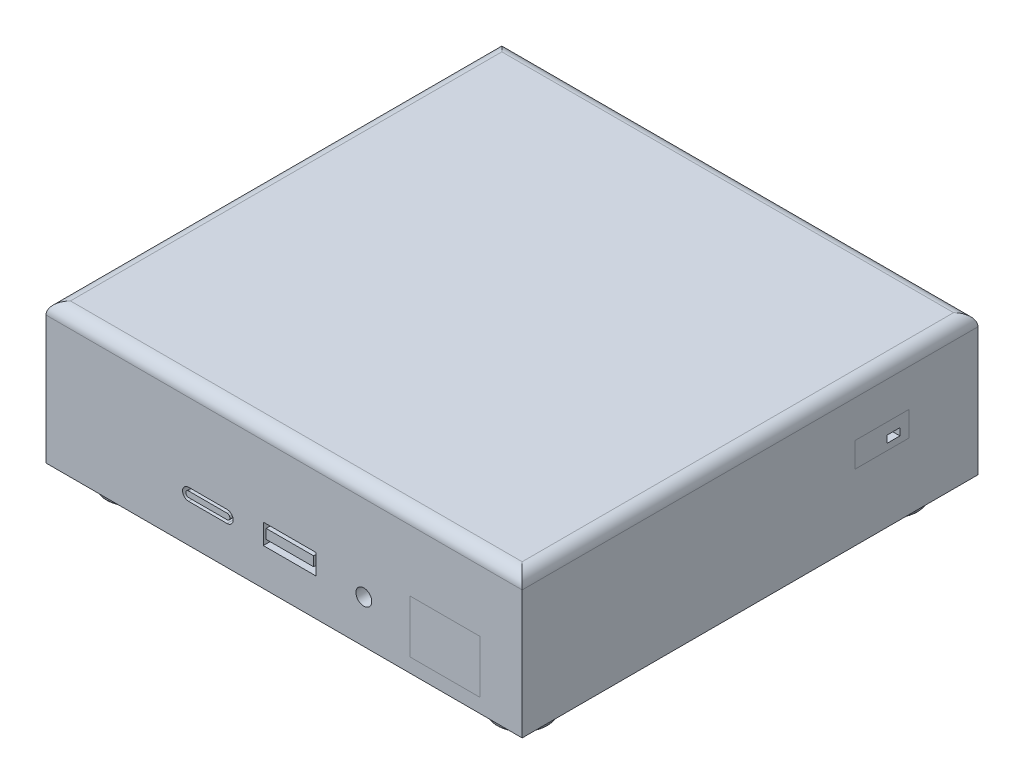
from build123d import *

# Parameters (mm, degrees)
SKETCH_2_W          = 117
SKETCH_2_H          = 112
EXTRUDE_1_DEPTH     = 34.5
FILLET_1_R          = 3
SKETCH_5_R          = 1.94319569
SKETCH_5_W          = 13
SKETCH_5_H          = 5
SKETCH_5_W_2        = 11.655581837
SKETCH_5_H_2        = 2.33697436
CUT_EXTRUDE_1_DEPTH = 34.5
SKETCH_7_W          = 3.12128514
SKETCH_7_H          = 1.749384405
CUT_EXTRUDE_2_DEPTH = 34.5
SKETCH_9_W          = 12.023305714
SKETCH_9_H          = 0.702782293
SKETCH_9_R          = 3.105468951
SKETCH_9_R_2        = 1.268882641
SKETCH_9_W_2        = 12.933693937
SKETCH_9_H_2        = 7.702330062
SKETCH_9_W_3        = 7.704150903
SKETCH_9_H_3        = 2.128244441
SKETCH_9_W_4        = 10.462177884
SKETCH_9_H_4        = 5.279264431
SKETCH_9_W_5        = 7
SKETCH_9_H_5        = 1.91211105
SKETCH_9_H_6        = 5.213763305
SKETCH_9_H_7        = 1.542759432
CUT_EXTRUDE_3_DEPTH = 34.5
SKETCH_11_W         = 26.414855416
SKETCH_11_H         = 1.499589485
CUT_EXTRUDE_4_DEPTH = 34.5
SKETCH_13_R         = 6.25
EXTRUDE_2_DEPTH     = 5
SKETCH_14_R         = 4
CUT_EXTRUDE_5_DEPTH = 5
SKETCH_15_R         = 1.5
CUT_EXTRUDE_6_DEPTH = 5
CUT_EXTRUDE_7_DEPTH = 1
FILLET_2_R          = 3
FILLET_3_R          = 0.5
SKETCH_17_R         = 1.25
CUT_EXTRUDE_8_DEPTH = 10


with BuildPart() as part:
    # 草图2 → 凸台-拉伸1 (new body)
    with BuildSketch(Plane(origin=(0, 0, 0), x_dir=(1, 0, 0), z_dir=(0, 1, 0))):
        Rectangle(SKETCH_2_W, SKETCH_2_H)
    extrude(amount=EXTRUDE_1_DEPTH)

    # 圆角1
    fillet_1_edges = [part.edges().sort_by_distance(p)[0] for p in [
        (-58.5, 34.5, 0),
        (0, 34.5, 56),
        (58.5, 34.5, 0),
        (0, 34.5, -56),
    ]]
    fillet(fillet_1_edges, radius=FILLET_1_R)

    # 草图5 → 切除-拉伸1 (cut)
    with BuildSketch(Plane.XY.offset(56)):
        with Locations((19.594569858, 10.537289657)):
            Circle(SKETCH_5_R)
        with Locations((1.387582533, 11.639469252)):
            Rectangle(SKETCH_5_W, SKETCH_5_H)
        with Locations((1.418326707, 11.970982072)):
            Rectangle(SKETCH_5_W_2, SKETCH_5_H_2, mode=Mode.SUBTRACT)
        with BuildLine():
            Line((-23.453277439, 12.376301325), (-14.013410674, 12.376301325))
            ThreePointArc((-14.013410674, 12.376301325), (-12.513410674, 10.876301325), (-14.013410674, 9.376301325))
            Line((-14.013410674, 9.376301325), (-23.453277439, 9.376301325))
            ThreePointArc((-23.453277439, 9.376301325), (-24.953277439, 10.876301325), (-23.453277439, 12.376301325))
        make_face()
        with BuildLine():
            Line((-23.453277439, 11.576301325), (-14.013410674, 11.576301325))
            ThreePointArc((-14.013410674, 11.576301325), (-13.313410674, 10.876301325), (-14.013410674, 10.176301325))
            Line((-14.013410674, 10.176301325), (-23.453277439, 10.176301325))
            ThreePointArc((-23.453277439, 10.176301325), (-24.153277439, 10.876301325), (-23.453277439, 11.576301325))
        make_face(mode=Mode.SUBTRACT)
    extrude(amount=-CUT_EXTRUDE_1_DEPTH, mode=Mode.SUBTRACT)

    # 草图7 → 切除-拉伸2 (cut)
    with BuildSketch(Plane(origin=(58.5, 0, 0), x_dir=(0, 0, -1), z_dir=(1, 0, 0))):
        with Locations((35.251062041, 18.745661738)):
            Rectangle(SKETCH_7_W, SKETCH_7_H)
    extrude(amount=-CUT_EXTRUDE_2_DEPTH, mode=Mode.SUBTRACT)

    # 草图9 → 切除-拉伸3 (cut)
    with BuildSketch(Plane(origin=(0, 0, -56), x_dir=(-1, 0, 0), z_dir=(0, 0, -1))):
        with BuildLine():
            ThreePointArc((-35.950498544, 11.544599726), (-34.777577949, 12.001879174), (-34.223677194, 13.132384002))
            Line((-34.223677194, 13.132384002), (-27.359684331, 13.132384002))
            Line((-27.359684331, 13.132384002), (-19.927828097, 13.132384002))
            ThreePointArc((-19.927828097, 13.132384002), (-19.656996341, 12.194159761), (-18.927828097, 11.544599726))
            Line((-18.927828097, 11.544599726), (-18.927828097, 8.613731529))
            Line((-18.927828097, 8.613731529), (-35.950498544, 8.613731529))
            Line((-35.950498544, 8.613731529), (-35.950498544, 11.544599726))
        make_face()
        with Locations((-26.730939637, 10.073758574)):
            Rectangle(SKETCH_9_W, SKETCH_9_H, mode=Mode.SUBTRACT)
        with Locations((-47.942536707, 10.42514972)):
            Circle(SKETCH_9_R)
        with Locations((-47.942536707, 10.42514972)):
            Circle(SKETCH_9_R_2, mode=Mode.SUBTRACT)
        with Locations((-3.756830225, 12.46489656)):
            Rectangle(SKETCH_9_W_2, SKETCH_9_H_2)
        with Locations((-3.075752646, 7.549609309)):
            Rectangle(SKETCH_9_W_3, SKETCH_9_H_3)
        with Locations((16.303260845, 13.676429375)):
            Rectangle(SKETCH_9_W_4, SKETCH_9_H_4)
        with Locations((16.276322806, 14.632484901)):
            Rectangle(SKETCH_9_W_5, SKETCH_9_H_5, mode=Mode.SUBTRACT)
        with Locations((16.303260845, 6.006849877)):
            Rectangle(SKETCH_9_W_4, SKETCH_9_H_6)
        with Locations((16.276322806, 6.778229593)):
            Rectangle(SKETCH_9_W_5, SKETCH_9_H_7, mode=Mode.SUBTRACT)
        with BuildLine():
            Line((31.367178921, 13.835844061), (38.401088463, 13.835844061))
            ThreePointArc((38.401088463, 13.835844061), (40.153784829, 15.588540426), (38.401088463, 17.341236792))
            Line((38.401088463, 17.341236792), (31.367178921, 17.341236792))
            ThreePointArc((31.367178921, 17.341236792), (29.614482555, 15.588540426), (31.367178921, 13.835844061))
        make_face()
        with BuildLine():
            ThreePointArc((38.401088463, 15.199333705), (38.790295184, 15.588540426), (38.401088463, 15.977747147))
            Line((38.401088463, 15.977747147), (31.367178921, 15.977747147))
            ThreePointArc((31.367178921, 15.977747147), (30.977972199, 15.588540426), (31.367178921, 15.199333705))
            Line((31.367178921, 15.199333705), (38.401088463, 15.199333705))
        make_face(mode=Mode.SUBTRACT)
        with BuildLine():
            Line((35.072171903, 20.278921559), (36.776322806, 20.278921559))
            ThreePointArc((36.776322806, 20.278921559), (37.483429588, 20.571814778), (37.776322806, 21.278921559))
            Line((37.776322806, 21.278921559), (37.776322806, 26.966804486))
            ThreePointArc((37.776322806, 26.966804486), (37.483429588, 27.673911268), (36.776322806, 27.966804486))
            Line((36.776322806, 27.966804486), (35.072171903, 27.966804486))
            ThreePointArc((35.072171903, 27.966804486), (34.365065122, 27.673911268), (34.072171903, 26.966804486))
            Line((34.072171903, 26.966804486), (34.072171903, 21.278921559))
            ThreePointArc((34.072171903, 21.278921559), (34.365065122, 20.571814778), (35.072171903, 20.278921559))
        make_face()
        with BuildLine():
            Line((29.072171903, 20.278921559), (30.776322806, 20.278921559))
            ThreePointArc((30.776322806, 20.278921559), (31.483429588, 20.571814778), (31.776322806, 21.278921559))
            Line((31.776322806, 21.278921559), (31.776322806, 26.966804486))
            ThreePointArc((31.776322806, 26.966804486), (31.483429588, 27.673911268), (30.776322806, 27.966804486))
            Line((30.776322806, 27.966804486), (29.072171903, 27.966804486))
            ThreePointArc((29.072171903, 27.966804486), (28.365065122, 27.673911268), (28.072171903, 26.966804486))
            Line((28.072171903, 26.966804486), (28.072171903, 21.278921559))
            ThreePointArc((28.072171903, 21.278921559), (28.365065122, 20.571814778), (29.072171903, 20.278921559))
        make_face()
        with BuildLine():
            Line((23.072171903, 20.278921559), (24.776322806, 20.278921559))
            ThreePointArc((24.776322806, 20.278921559), (25.483429588, 20.571814778), (25.776322806, 21.278921559))
            Line((25.776322806, 21.278921559), (25.776322806, 26.966804486))
            ThreePointArc((25.776322806, 26.966804486), (25.483429588, 27.673911268), (24.776322806, 27.966804486))
            Line((24.776322806, 27.966804486), (23.072171903, 27.966804486))
            ThreePointArc((23.072171903, 27.966804486), (22.365065122, 27.673911268), (22.072171903, 26.966804486))
            Line((22.072171903, 26.966804486), (22.072171903, 21.278921559))
            ThreePointArc((22.072171903, 21.278921559), (22.365065122, 20.571814778), (23.072171903, 20.278921559))
        make_face()
        with BuildLine():
            Line((17.072171903, 20.278921559), (18.776322806, 20.278921559))
            ThreePointArc((18.776322806, 20.278921559), (19.483429588, 20.571814778), (19.776322806, 21.278921559))
            Line((19.776322806, 21.278921559), (19.776322806, 26.966804486))
            ThreePointArc((19.776322806, 26.966804486), (19.483429588, 27.673911268), (18.776322806, 27.966804486))
            Line((18.776322806, 27.966804486), (17.072171903, 27.966804486))
            ThreePointArc((17.072171903, 27.966804486), (16.365065122, 27.673911268), (16.072171903, 26.966804486))
            Line((16.072171903, 26.966804486), (16.072171903, 21.278921559))
            ThreePointArc((16.072171903, 21.278921559), (16.365065122, 20.571814778), (17.072171903, 20.278921559))
        make_face()
        with BuildLine():
            Line((11.072171903, 20.278921559), (12.776322806, 20.278921559))
            ThreePointArc((12.776322806, 20.278921559), (13.483429588, 20.571814778), (13.776322806, 21.278921559))
            Line((13.776322806, 21.278921559), (13.776322806, 26.966804486))
            ThreePointArc((13.776322806, 26.966804486), (13.483429588, 27.673911268), (12.776322806, 27.966804486))
            Line((12.776322806, 27.966804486), (11.072171903, 27.966804486))
            ThreePointArc((11.072171903, 27.966804486), (10.365065122, 27.673911268), (10.072171903, 26.966804486))
            Line((10.072171903, 26.966804486), (10.072171903, 21.278921559))
            ThreePointArc((10.072171903, 21.278921559), (10.365065122, 20.571814778), (11.072171903, 20.278921559))
        make_face()
        with BuildLine():
            Line((5.072171903, 20.278921559), (6.776322806, 20.278921559))
            ThreePointArc((6.776322806, 20.278921559), (7.483429588, 20.571814778), (7.776322806, 21.278921559))
            Line((7.776322806, 21.278921559), (7.776322806, 26.966804486))
            ThreePointArc((7.776322806, 26.966804486), (7.483429588, 27.673911268), (6.776322806, 27.966804486))
            Line((6.776322806, 27.966804486), (5.072171903, 27.966804486))
            ThreePointArc((5.072171903, 27.966804486), (4.365065122, 27.673911268), (4.072171903, 26.966804486))
            Line((4.072171903, 26.966804486), (4.072171903, 21.278921559))
            ThreePointArc((4.072171903, 21.278921559), (4.365065122, 20.571814778), (5.072171903, 20.278921559))
        make_face()
        with BuildLine():
            Line((-0.927828097, 20.278921559), (0.776322806, 20.278921559))
            ThreePointArc((0.776322806, 20.278921559), (1.483429588, 20.571814778), (1.776322806, 21.278921559))
            Line((1.776322806, 21.278921559), (1.776322806, 26.966804486))
            ThreePointArc((1.776322806, 26.966804486), (1.483429588, 27.673911268), (0.776322806, 27.966804486))
            Line((0.776322806, 27.966804486), (-0.927828097, 27.966804486))
            ThreePointArc((-0.927828097, 27.966804486), (-1.634934878, 27.673911268), (-1.927828097, 26.966804486))
            Line((-1.927828097, 26.966804486), (-1.927828097, 21.278921559))
            ThreePointArc((-1.927828097, 21.278921559), (-1.634934878, 20.571814778), (-0.927828097, 20.278921559))
        make_face()
        with BuildLine():
            Line((-6.927828097, 20.278921559), (-5.223677194, 20.278921559))
            ThreePointArc((-5.223677194, 20.278921559), (-4.516570412, 20.571814778), (-4.223677194, 21.278921559))
            Line((-4.223677194, 21.278921559), (-4.223677194, 26.966804486))
            ThreePointArc((-4.223677194, 26.966804486), (-4.516570412, 27.673911268), (-5.223677194, 27.966804486))
            Line((-5.223677194, 27.966804486), (-6.927828097, 27.966804486))
            ThreePointArc((-6.927828097, 27.966804486), (-7.634934878, 27.673911268), (-7.927828097, 26.966804486))
            Line((-7.927828097, 26.966804486), (-7.927828097, 21.278921559))
            ThreePointArc((-7.927828097, 21.278921559), (-7.634934878, 20.571814778), (-6.927828097, 20.278921559))
        make_face()
        with BuildLine():
            Line((-12.927828097, 20.278921559), (-11.223677194, 20.278921559))
            ThreePointArc((-11.223677194, 20.278921559), (-10.516570412, 20.571814778), (-10.223677194, 21.278921559))
            Line((-10.223677194, 21.278921559), (-10.223677194, 26.966804486))
            ThreePointArc((-10.223677194, 26.966804486), (-10.516570412, 27.673911268), (-11.223677194, 27.966804486))
            Line((-11.223677194, 27.966804486), (-12.927828097, 27.966804486))
            ThreePointArc((-12.927828097, 27.966804486), (-13.634934878, 27.673911268), (-13.927828097, 26.966804486))
            Line((-13.927828097, 26.966804486), (-13.927828097, 21.278921559))
            ThreePointArc((-13.927828097, 21.278921559), (-13.634934878, 20.571814778), (-12.927828097, 20.278921559))
        make_face()
        with BuildLine():
            Line((-18.927828097, 20.278921559), (-17.223677194, 20.278921559))
            ThreePointArc((-17.223677194, 20.278921559), (-16.516570412, 20.571814778), (-16.223677194, 21.278921559))
            Line((-16.223677194, 21.278921559), (-16.223677194, 26.966804486))
            ThreePointArc((-16.223677194, 26.966804486), (-16.516570412, 27.673911268), (-17.223677194, 27.966804486))
            Line((-17.223677194, 27.966804486), (-18.927828097, 27.966804486))
            ThreePointArc((-18.927828097, 27.966804486), (-19.634934878, 27.673911268), (-19.927828097, 26.966804486))
            Line((-19.927828097, 26.966804486), (-19.927828097, 21.278921559))
            ThreePointArc((-19.927828097, 21.278921559), (-19.634934878, 20.571814778), (-18.927828097, 20.278921559))
        make_face()
        with BuildLine():
            Line((-24.927828097, 20.278921559), (-23.223677194, 20.278921559))
            ThreePointArc((-23.223677194, 20.278921559), (-22.516570412, 20.571814778), (-22.223677194, 21.278921559))
            Line((-22.223677194, 21.278921559), (-22.223677194, 26.966804486))
            ThreePointArc((-22.223677194, 26.966804486), (-22.516570412, 27.673911268), (-23.223677194, 27.966804486))
            Line((-23.223677194, 27.966804486), (-24.927828097, 27.966804486))
            ThreePointArc((-24.927828097, 27.966804486), (-25.634934878, 27.673911268), (-25.927828097, 26.966804486))
            Line((-25.927828097, 26.966804486), (-25.927828097, 21.278921559))
            ThreePointArc((-25.927828097, 21.278921559), (-25.634934878, 20.571814778), (-24.927828097, 20.278921559))
        make_face()
        with BuildLine():
            Line((-30.927828097, 20.278921559), (-29.223677194, 20.278921559))
            ThreePointArc((-29.223677194, 20.278921559), (-28.516570412, 20.571814778), (-28.223677194, 21.278921559))
            Line((-28.223677194, 21.278921559), (-28.223677194, 26.966804486))
            ThreePointArc((-28.223677194, 26.966804486), (-28.516570412, 27.673911268), (-29.223677194, 27.966804486))
            Line((-29.223677194, 27.966804486), (-30.927828097, 27.966804486))
            ThreePointArc((-30.927828097, 27.966804486), (-31.634934878, 27.673911268), (-31.927828097, 26.966804486))
            Line((-31.927828097, 26.966804486), (-31.927828097, 21.278921559))
            ThreePointArc((-31.927828097, 21.278921559), (-31.634934878, 20.571814778), (-30.927828097, 20.278921559))
        make_face()
        with BuildLine():
            Line((-36.927828097, 20.278921559), (-35.223677194, 20.278921559))
            ThreePointArc((-35.223677194, 20.278921559), (-34.516570412, 20.571814778), (-34.223677194, 21.278921559))
            Line((-34.223677194, 21.278921559), (-34.223677194, 26.966804486))
            ThreePointArc((-34.223677194, 26.966804486), (-34.516570412, 27.673911268), (-35.223677194, 27.966804486))
            Line((-35.223677194, 27.966804486), (-36.927828097, 27.966804486))
            ThreePointArc((-36.927828097, 27.966804486), (-37.634934878, 27.673911268), (-37.927828097, 26.966804486))
            Line((-37.927828097, 26.966804486), (-37.927828097, 21.278921559))
            ThreePointArc((-37.927828097, 21.278921559), (-37.634934878, 20.571814778), (-36.927828097, 20.278921559))
        make_face()
        with BuildLine():
            ThreePointArc((-43.927828097, 26.966804486), (-43.634934878, 27.673911268), (-42.927828097, 27.966804486))
            Line((-42.927828097, 27.966804486), (-41.223677194, 27.966804486))
            ThreePointArc((-41.223677194, 27.966804486), (-40.516570412, 27.673911268), (-40.223677194, 26.966804486))
            Line((-40.223677194, 26.966804486), (-40.223677194, 21.278921559))
            ThreePointArc((-40.223677194, 21.278921559), (-40.516570412, 20.571814778), (-41.223677194, 20.278921559))
            Line((-41.223677194, 20.278921559), (-42.927828097, 20.278921559))
            ThreePointArc((-42.927828097, 20.278921559), (-43.634934878, 20.571814778), (-43.927828097, 21.278921559))
            Line((-43.927828097, 21.278921559), (-43.927828097, 26.966804486))
        make_face()
    extrude(amount=-CUT_EXTRUDE_3_DEPTH, mode=Mode.SUBTRACT)

    # 草图11 → 切除-拉伸4 (cut)
    with BuildSketch(Plane.ZY.offset(58.5)):
        with Locations((27.293913372, 15.341122477)):
            Rectangle(SKETCH_11_W, SKETCH_11_H)
    extrude(amount=-CUT_EXTRUDE_4_DEPTH, mode=Mode.SUBTRACT)

    # 草图13 → 凸台-拉伸2 (add)
    with BuildSketch(Plane.XZ):
        with Locations((48, 45.5)):
            Circle(SKETCH_13_R)
        with Locations((48, -45.5)):
            Circle(SKETCH_13_R)
        with Locations((-48, 45.5)):
            Circle(SKETCH_13_R)
        with Locations((-48, -45.5)):
            Circle(SKETCH_13_R)
    extrude(amount=EXTRUDE_2_DEPTH)

    # 草图14 → 切除-拉伸5 (cut)
    with BuildSketch(Plane.XZ.offset(5)):
        with Locations((48, 45.5)):
            Circle(SKETCH_14_R)
        with Locations((48, -45.5)):
            Circle(SKETCH_14_R)
        with Locations((-48, 45.5)):
            Circle(SKETCH_14_R)
        with Locations((-48, -45.5)):
            Circle(SKETCH_14_R)
    extrude(amount=-CUT_EXTRUDE_5_DEPTH, mode=Mode.SUBTRACT)

    # 草图15 → 切除-拉伸6 (cut)
    with BuildSketch(Plane.XZ):
        with Locations((0, 42.5)):
            Circle(SKETCH_15_R)
        with Locations((0, -42.5)):
            Circle(SKETCH_15_R)
    extrude(amount=-CUT_EXTRUDE_6_DEPTH, mode=Mode.SUBTRACT)

    # 草图16 → 切除-拉伸7 (cut)
    with BuildSketch(Plane.XZ):
        with BuildLine():
            ThreePointArc((33, -45.5), (37.393398282, -34.893398282), (48, -30.5))
            Line((48, -30.5), (48, 30.5))
            ThreePointArc((48, 30.5), (37.393398282, 34.893398282), (33, 45.5))
            Line((33, 45.5), (11.971550157, 45.5))
            Line((11.971550157, 45.5), (4.383302564, 37.30509973))
            Line((4.383302564, 37.30509973), (3.340411246, 37.30509973))
            Line((3.340411246, 37.30509973), (-3.340411246, 37.30509973))
            Line((-3.340411246, 37.30509973), (-4.383302564, 37.30509973))
            Line((-4.383302564, 37.30509973), (-11.971550157, 45.5))
            Line((-11.971550157, 45.5), (-33, 45.5))
            ThreePointArc((-33, 45.5), (-37.393398282, 34.893398282), (-48, 30.5))
            Line((-48, 30.5), (-48, -30.5))
            ThreePointArc((-48, -30.5), (-37.393398282, -34.893398282), (-33, -45.5))
            Line((-33, -45.5), (-11.971550157, -45.5))
            Line((-11.971550157, -45.5), (-4.383302564, -37.30509973))
            Line((-4.383302564, -37.30509973), (-3.340411246, -37.30509973))
            Line((-3.340411246, -37.30509973), (3.340411246, -37.30509973))
            Line((3.340411246, -37.30509973), (4.383302564, -37.30509973))
            Line((4.383302564, -37.30509973), (11.971550157, -45.5))
            Line((11.971550157, -45.5), (33, -45.5))
        make_face()
    extrude(amount=-CUT_EXTRUDE_7_DEPTH, mode=Mode.SUBTRACT)

    # 圆角2
    fillet_2_edges = [part.edges().sort_by_distance(p)[0] for p in [
        (-48, 0.5, 30.5),
        (-33, 0.5, 45.5),
        (-11.971550157, 0.5, 45.5),
        (-4.383302564, 0.5, 37.30509973),
        (4.383302564, 0.5, 37.30509973),
        (11.971550157, 0.5, 45.5),
        (33, 0.5, 45.5),
        (48, 0.5, 30.5),
        (48, 0.5, -30.5),
        (33, 0.5, -45.5),
        (11.971550157, 0.5, -45.5),
        (4.383302564, 0.5, -37.30509973),
        (-4.383302564, 0.5, -37.30509973),
        (-11.971550157, 0.5, -45.5),
        (-33, 0.5, -45.5),
        (-48, 0.5, -30.5),
    ]]
    fillet(fillet_2_edges, radius=FILLET_2_R)

    # 圆角3
    fillet_3_edges = [part.edges().sort_by_distance(p)[0] for p in [
        (41.75, -5, 45.5),
        (41.75, -5, -45.5),
        (-54.25, -5, 45.5),
        (-54.25, -5, -45.5),
        (44, -5, -45.5),
        (-52, -5, 45.5),
        (-52, -5, -45.5),
        (44, -5, 45.5),
    ]]
    fillet(fillet_3_edges, radius=FILLET_3_R)

    # 草图17 → 切除-拉伸8 (cut)
    with BuildSketch(Plane.XZ):
        with Locations((48, 45.5)):
            Circle(SKETCH_17_R)
        with Locations((48, -45.5)):
            Circle(SKETCH_17_R)
        with Locations((-48, 45.5)):
            Circle(SKETCH_17_R)
        with Locations((-48, -45.5)):
            Circle(SKETCH_17_R)
    extrude(amount=-CUT_EXTRUDE_8_DEPTH, mode=Mode.SUBTRACT)


solid = part.part
